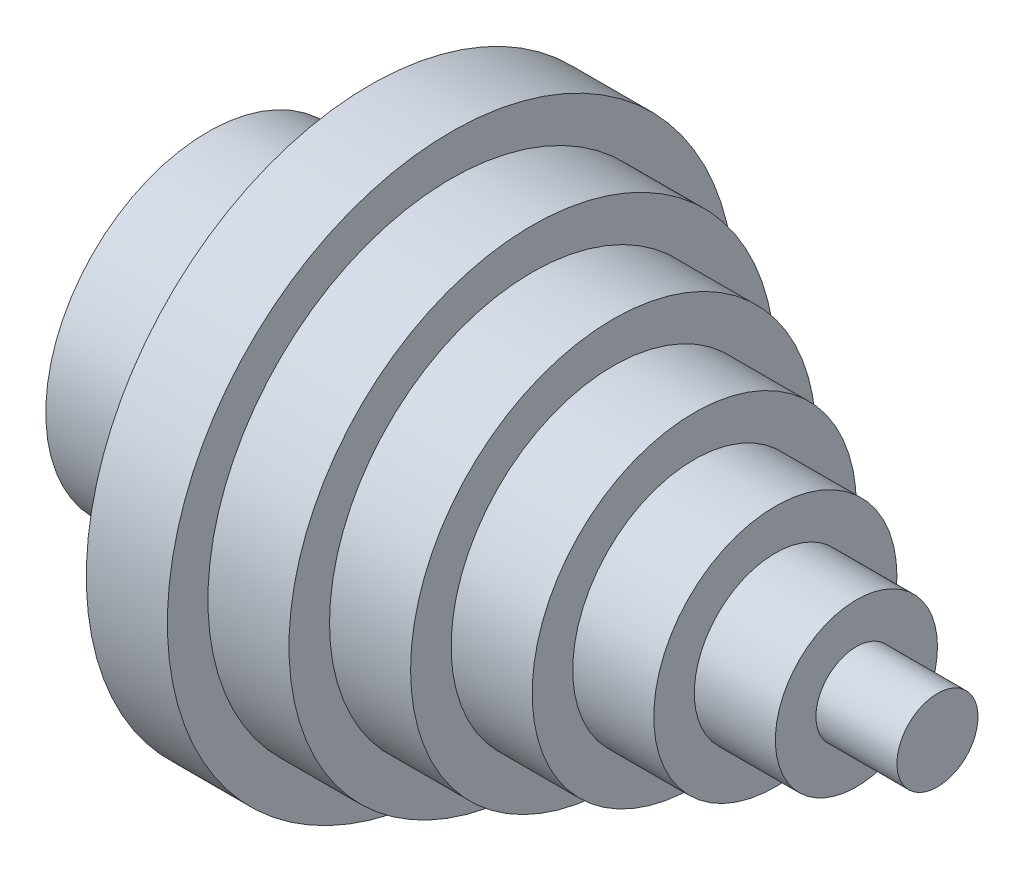
from build123d import *

# Parameters (mm, degrees)
SKETCH2_R          = 30
CUT_EXTRUDE1_DEPTH = 40


with BuildPart() as part:
    # Sketch1 → Revolve1 (revolve)
    with BuildSketch(Plane.XY, mode=Mode.PRIVATE) as revolve1_sk:
        Polygon((0, 0), (0, 10), (-20, 10), (-20, 20), (-40, 20), (-40, 30), (-60, 30), (-60, 40), (-80, 40), (-80, 50), (-100, 50), (-100, 60), (-120, 60), (-120, 70), (-140, 70), (-140, 40), (-180, 40), (-180, 0), align=None)
    revolve(revolve1_sk.sketch.rotate(Axis((0, 0, 0), (-1, 0, 0)), 90), axis=Axis((0, 0, 0), (-1, 0, 0)))  # turned: the seam where the file's is

    # Sketch2 → Cut-Extrude1 (cut)
    with BuildSketch(Plane.ZY.offset(180)):
        with Locations(Location((0, 0, 0), (0, 0, 180))):  # turned: the seam where the file's is
            Circle(SKETCH2_R)
    extrude(amount=-CUT_EXTRUDE1_DEPTH, mode=Mode.SUBTRACT)


solid = part.part
